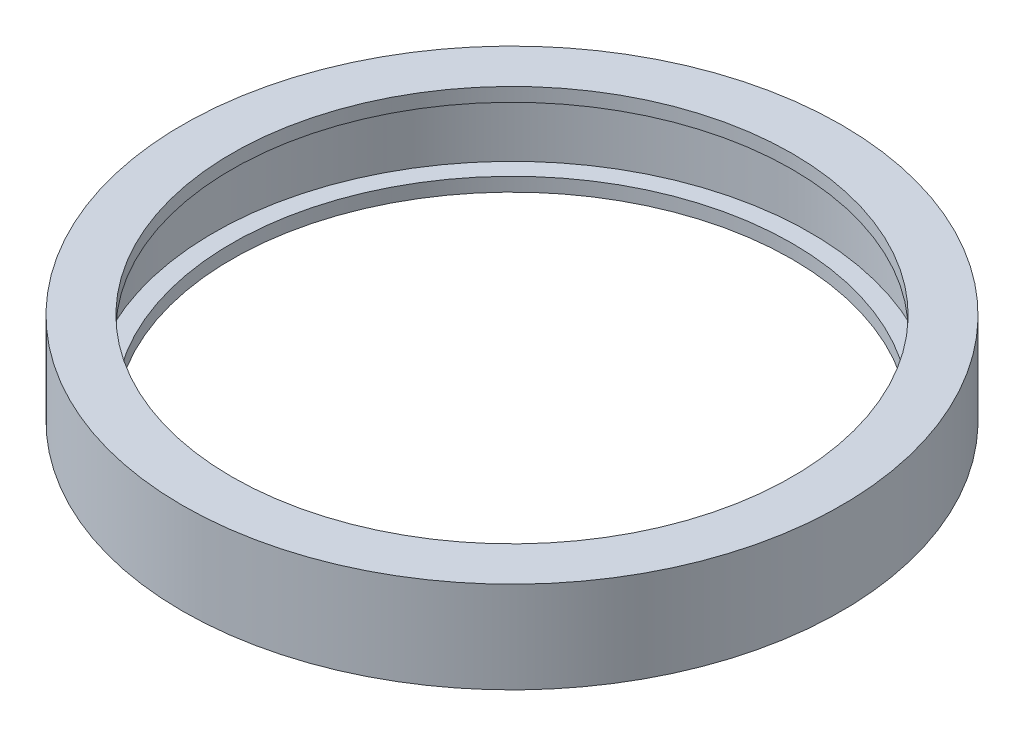
from build123d import *

# Parameters (mm, degrees)
SKETCH1_R           = 36
SKETCH1_R_2         = 30.6
BOSS_EXTRUDE1_DEPTH = 5
SKETCH2_R           = 32.6
CUT_EXTRUDE1_DEPTH  = 3.5


with BuildPart() as part:
    # Sketch1 → Boss-Extrude1 (new body, symmetric)
    with BuildSketch(Plane(origin=(0, 0, 0), x_dir=(1, 0, 0), z_dir=(0, 1, 0))):
        Circle(SKETCH1_R)
        Circle(SKETCH1_R_2, mode=Mode.SUBTRACT)
    extrude(amount=BOSS_EXTRUDE1_DEPTH, both=True)

    # Sketch2 → Cut-Extrude1 (cut, symmetric)
    with BuildSketch(Plane(origin=(0, 0, 0), x_dir=(1, 0, 0), z_dir=(0, 1, 0))):
        Circle(SKETCH2_R)
    extrude(amount=CUT_EXTRUDE1_DEPTH, both=True, mode=Mode.SUBTRACT)


solid = part.part
